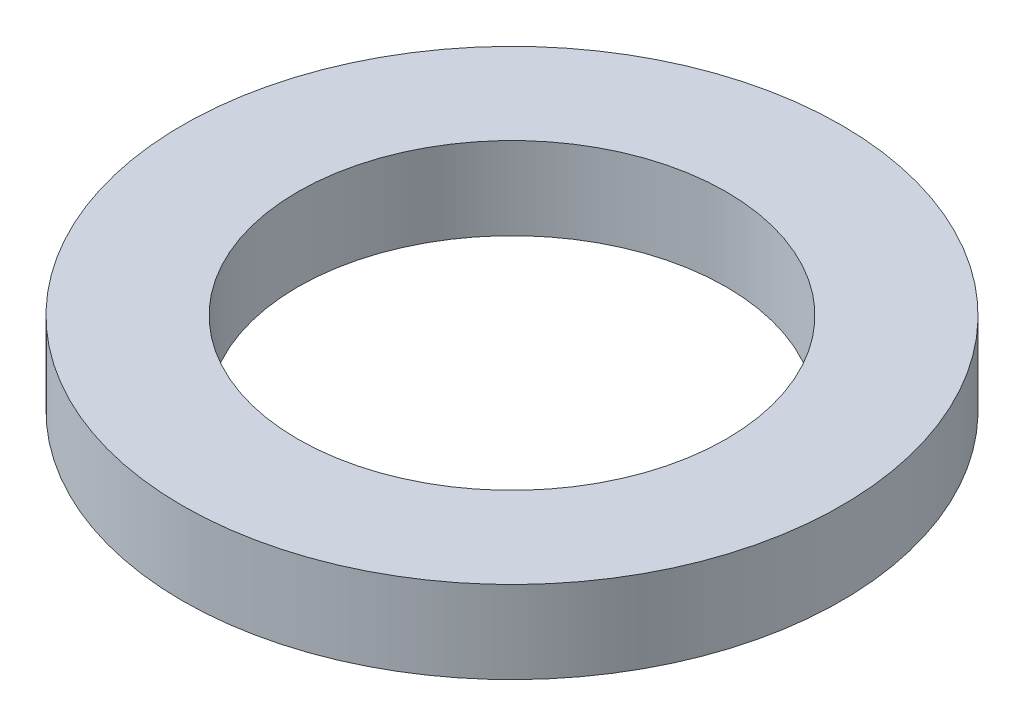
from build123d import *

# Parameters (mm, degrees)
SKETCH1_R           = 4
SKETCH1_R_2         = 2.6
BOSS_EXTRUDE1_DEPTH = 1


with BuildPart() as part:
    # Sketch1 → Boss-Extrude1 (new body)
    with BuildSketch(Plane(origin=(0, 0, 0), x_dir=(1, 0, 0), z_dir=(0, 1, 0))):
        Circle(SKETCH1_R)
        Circle(SKETCH1_R_2, mode=Mode.SUBTRACT)
    extrude(amount=BOSS_EXTRUDE1_DEPTH)


solid = part.part
